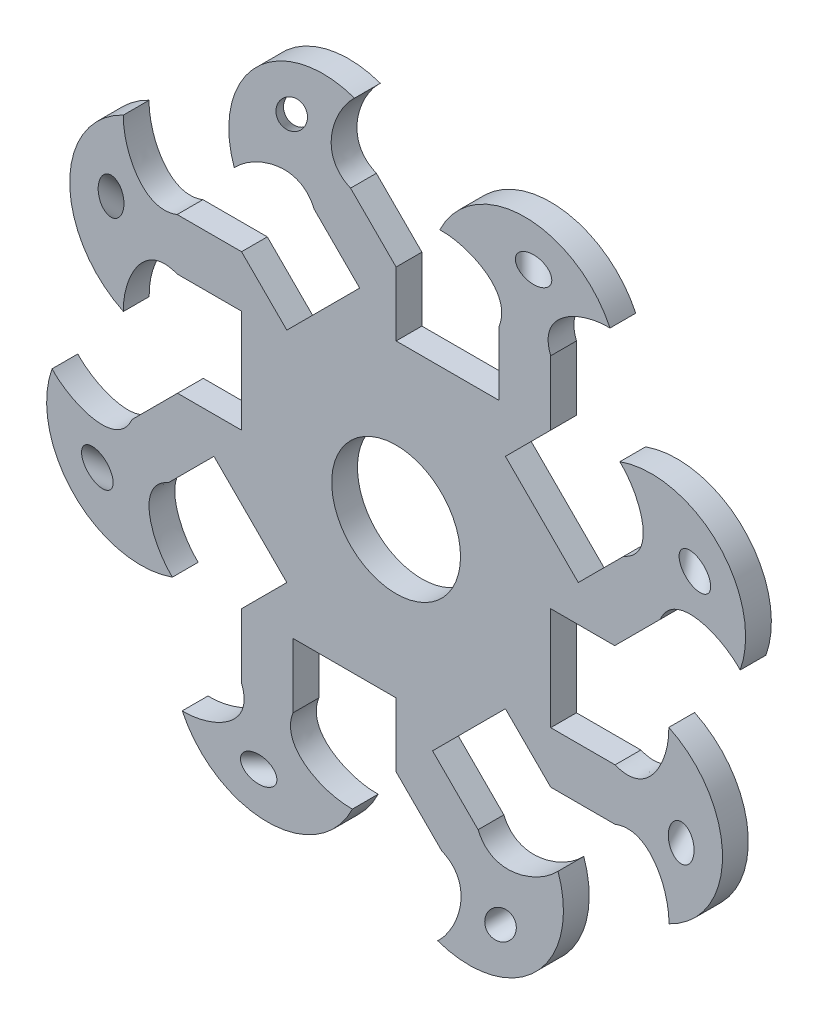
from build123d import *

# Parameters (mm, degrees)
SKETCH1_R           = 2.5
BOSS_EXTRUDE1_DEPTH = 1
BOSS_EXTRUDE2_DEPTH = 1
CUT_EXTRUDE1_START  = -1
SKETCH5_R           = 0.5
CUT_EXTRUDE1_DEPTH  = 20.707970143
CIRPATTERN4_COUNT   = 8


with BuildPart() as part:
    # Sketch1 → Boss-Extrude1 (new body)
    with BuildSketch(Plane.XY):
        Polygon((-6, 0), (-6, 4.000001453), (-8.5, 4.000001453), (-8.5, 6), (-6, 6), (-4.242640687, 4.242640687), (-1.414212535, 7.071068839), (-3.181979488, 8.838835792), (-1.767766953, 10.253048327), (0, 8.485281374), (0, 6), (4.000001453, 6), (4.000001453, 8.5), (6, 8.5), (6, 6), (4.242640687, 4.242640687), (7.071068839, 1.414212535), (8.838835792, 3.181979488), (10.253048327, 1.767766953), (8.485281374, 0), (6, 0), (6, -4.000001453), (8.5, -4.000001453), (8.5, -6), (6, -6), (4.242640687, -4.242640687), (1.414212535, -7.071068839), (3.181979488, -8.838835792), (1.767766953, -10.253048327), (0, -8.485281374), (0, -6), (-4.000001453, -6), (-4.000001453, -8.5), (-6, -8.5), (-6, -6), (-4.242640687, -4.242640687), (-7.071068839, -1.414212535), (-8.838835792, -3.181979488), (-10.253048327, -1.767766953), (-8.485281374, 0), align=None)
        Circle(SKETCH1_R, mode=Mode.SUBTRACT)
    extrude(amount=-BOSS_EXTRUDE1_DEPTH)

    # Sketch2 → Boss-Extrude2 (add)
    with BuildSketch(Plane.XY):
        with BuildLine():
            Line((6, 8.5), (4.000001453, 8.5))
            add(Edge.make_bspline(
                [(4.000001453, 8.5), (4.535044761, 9.851871254), (2.785677296, 10.626331859), (1.69748686, 10.584769031)],
                knots=[0, 0, 0, 0, 1, 1, 1, 1], degree=3))
            ThreePointArc((1.69748686, 10.584769031), (5.000000726, 12.6701636), (8.302514593, 10.584769031))
            add(Edge.make_bspline(
                [(6, 8.5), (5.464956692, 9.851871254), (7.214324157, 10.626331859), (8.302514593, 10.584769031)],
                knots=[0, 0, 0, 0, 1, 1, 1, 1], degree=3))
        make_face()
    boss_extrude2 = extrude(amount=-BOSS_EXTRUDE2_DEPTH)

    # Sketch5 → Cut-Extrude1 (cut)
    with BuildSketch(Plane(origin=(-8.102008287, 0, -8.102008287), x_dir=(0, -1, 0), z_dir=(0.707106781, 0, 0.707106781)).offset(CUT_EXTRUDE1_START)):
        with Locations((-11.065369039, 3.772340366)):
            Circle(SKETCH5_R)
    cut_extrude1 = extrude(amount=CUT_EXTRUDE1_DEPTH, mode=Mode.SUBTRACT)

    # CirPattern4: Boss-Extrude2, Cut-Extrude1 ×8 about axis
    cirpattern4_axis = Axis((0, 0, 0), (0, 0, 1))
    for i in range(1, CIRPATTERN4_COUNT):
        add(boss_extrude2.rotate(cirpattern4_axis, i * 360 / CIRPATTERN4_COUNT))
        add(cut_extrude1.rotate(cirpattern4_axis, i * 360 / CIRPATTERN4_COUNT), mode=Mode.SUBTRACT)


solid = part.part
